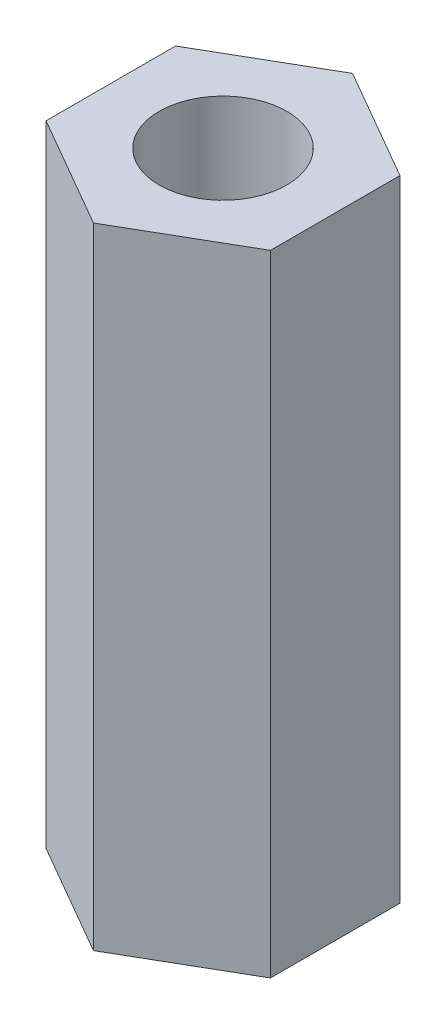
from build123d import *

# Parameters (mm, degrees)
SKETCH_1_R      = 1.5
EXTRUDE_1_DEPTH = 14.8


with BuildPart() as part:
    # Эскиз1 → Бобышка-Вытянуть1 (new body)
    with BuildSketch(Plane(origin=(0, 0, 0), x_dir=(1, 0, 0), z_dir=(0, 1, 0))):
        Polygon((0, 3.042635919), (-2.635, 1.521317959), (-2.635, -1.521317959), (0, -3.042635919), (2.635, -1.521317959), (2.635, 1.521317959), align=None)
        Circle(SKETCH_1_R, mode=Mode.SUBTRACT)
    extrude(amount=EXTRUDE_1_DEPTH)


solid = part.part
